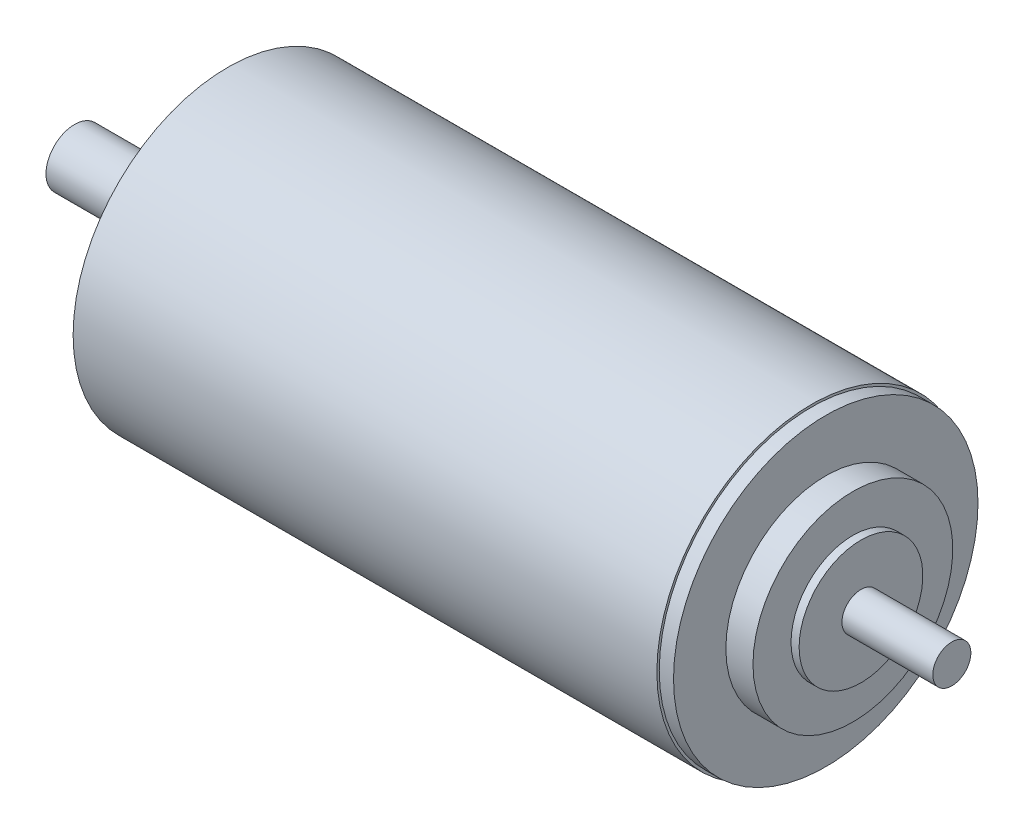
from build123d import *


with BuildPart() as part:
    # Esquisse1 → Révolution1 (revolve)
    with BuildSketch(Plane.XY):
        Polygon((0, 0), (0, 6), (28.1, 6), (28.1, 18), (32.2, 18), (32.2, 32.5), (154.9, 32.5), (154.9, 32), (157.9, 32), (157.9, 21), (163.6, 21), (163.6, 13), (165.3, 13), (165.3, 4), (184.4, 4), (184.4, 0), align=None)
    revolve(axis=Axis((0, 0, 0), (1, 0, 0)))


solid = part.part
